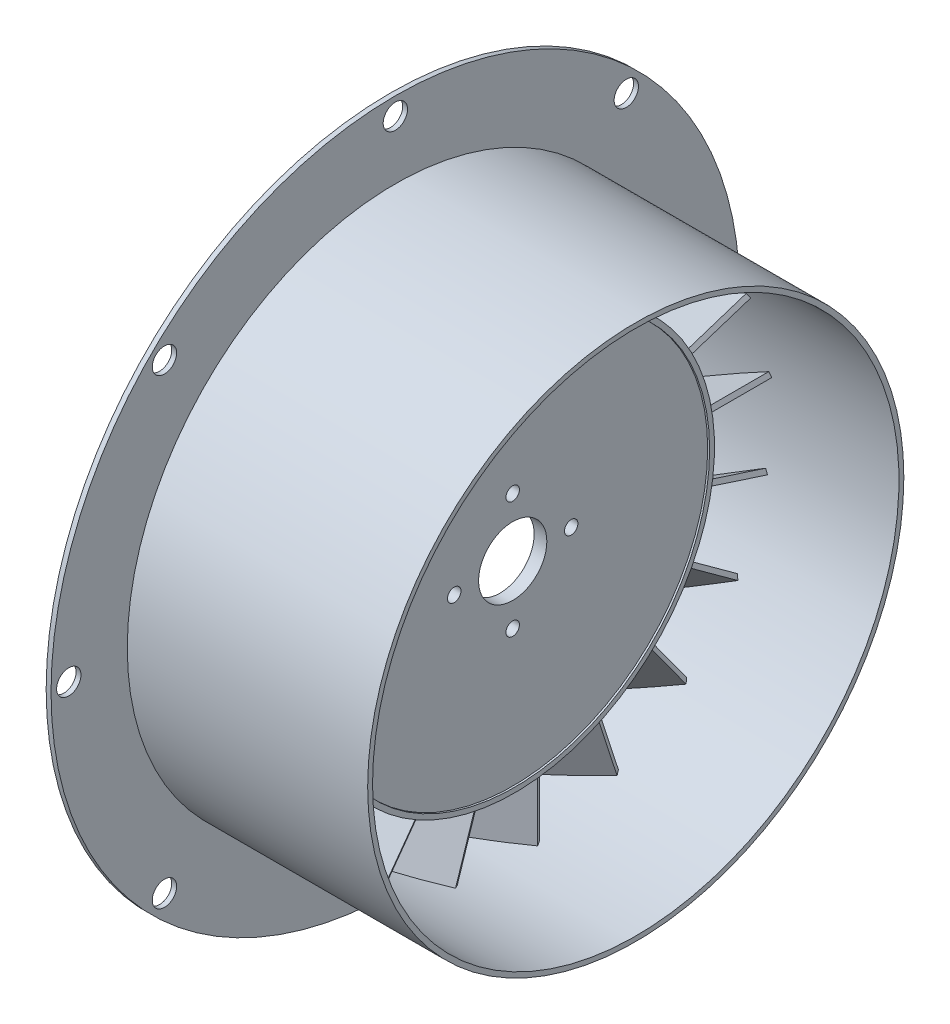
from build123d import *

# Parameters (mm, degrees)
BOSS_EXTRUDE1_REACH        = 166.235
BOSS_EXTRUDE1_START_RADIUS = 52.07
BOSS_EXTRUDE1_END_RADIUS   = 52.07
CIRPATTERN15_COUNT         = 20
SKETCH7_R                  = 1.7526
SKETCH7_R_2                = 8.89
CUT_EXTRUDE1_DEPTH         = 102.14463705
SKETCH9_R                  = 3.175
CUT_EXTRUDE2_DEPTH         = 2.54


with BuildPart() as part:
    # Sketch1 → Revolve1 (revolve)
    with BuildSketch(Plane(origin=(0, 0, 0), x_dir=(1, 0, 0), z_dir=(0, 1, 0)), mode=Mode.PRIVATE) as revolve1_sk:
        Polygon((3.302, 0), (3.302, 50.8), (3.81, 50.8), (3.81, 52.07), (-25.4, 52.07), (-25.4, 50.8), (0, 50.8), (0, 0), align=None)
    revolve(revolve1_sk.sketch.rotate(Axis((0, 0, 0), (1, 0, 0)), 180), axis=Axis((0, 0, 0), (1, 0, 0)))

    # Boss-Extrude1: from a cylinder face, 166.235 long prism both ways, kept between that surface and its translate by the depth
    boss_extrude1_start = Plane(origin=(-10.795, 0, 0), z_dir=(-1, 0, 0)) * Cylinder(BOSS_EXTRUDE1_START_RADIUS, 437.61, mode=Mode.PRIVATE)
    boss_extrude1_end = Plane(origin=(-10.795, 0, 16.51), z_dir=(-1, 0, 0)) * Cylinder(BOSS_EXTRUDE1_END_RADIUS, 437.61, mode=Mode.PRIVATE)
    # Sketch2 → Boss-Extrude1 (add, from a surface)
    with BuildSketch(Plane.XY.offset(83.82), mode=Mode.PRIVATE) as boss_extrude1_sk1:
        Polygon((-24.310727154, 7.070073869), (2.085727154, -8.169926131), (2.720727154, -7.070073869), (-23.675727154, 8.169926131), align=None)
    boss_extrude1_tool1 = extrude(boss_extrude1_sk1.sketch, amount=BOSS_EXTRUDE1_REACH, both=True, mode=Mode.PRIVATE)
    boss_extrude1 = ((boss_extrude1_tool1 - boss_extrude1_start) & boss_extrude1_end).solids().sort_by_distance((-10.795, 0, 59.761422))[0]
    add(boss_extrude1)

    # CirPattern15: Boss-Extrude1 ×20 about axis
    cirpattern15_axis = Axis((0, 0, 0), (1, 0, 0))
    for i in range(1, CIRPATTERN15_COUNT):
        add(boss_extrude1.rotate(cirpattern15_axis, i * 360 / CIRPATTERN15_COUNT))

    # Sketch7 → Cut-Extrude1 (cut, through all)
    with BuildSketch(Plane(origin=(3.302, 0, 0), x_dir=(0, 0, -1), z_dir=(1, 0, 0))):
        with Locations((0, 15.24)):
            Circle(SKETCH7_R)
        Circle(SKETCH7_R_2)
        with Locations((15.24, 0)):
            Circle(SKETCH7_R)
        with Locations((0, -15.24)):
            Circle(SKETCH7_R)
        with Locations((-15.24, 0)):
            Circle(SKETCH7_R)
    extrude(amount=-CUT_EXTRUDE1_DEPTH, mode=Mode.SUBTRACT)


with BuildPart() as body_2:
    # Sketch8 → Revolve2 (revolve)
    with BuildSketch(Plane.XY, mode=Mode.PRIVATE) as revolve2_sk:
        Polygon((35.360589781, 69.85), (35.360589781, 68.58), (-28.539332901, 68.58), (-28.539332901, 89.716824123), (-27.269332901, 89.716824123), (-27.269332901, 69.85), align=None)
    revolve(revolve2_sk.sketch.rotate(Axis((0, 0, 0), (1, 0, 0)), 90), axis=Axis((0, 0, 0), (1, 0, 0)))

    # Sketch9 → Cut-Extrude2 (cut)
    with BuildSketch(Plane(origin=(-27.269332901, 0, 0), x_dir=(0, 0, -1), z_dir=(1, 0, 0))):
        with Locations((0, 85.09)):
            Circle(SKETCH9_R)
        with Locations((60.167716011, 60.167716011)):
            Circle(SKETCH9_R)
        with Locations((85.09, 0)):
            Circle(SKETCH9_R)
        with Locations((60.167716011, -60.167716011)):
            Circle(SKETCH9_R)
        with Locations((0, -85.09)):
            Circle(SKETCH9_R)
        with Locations((-60.167716011, -60.167716011)):
            Circle(SKETCH9_R)
        with Locations((-85.09, 0)):
            Circle(SKETCH9_R)
        with Locations((-60.167716011, 60.167716011)):
            Circle(SKETCH9_R)
    extrude(amount=-CUT_EXTRUDE2_DEPTH, mode=Mode.SUBTRACT)


solid = Compound([part.part, body_2.part])
